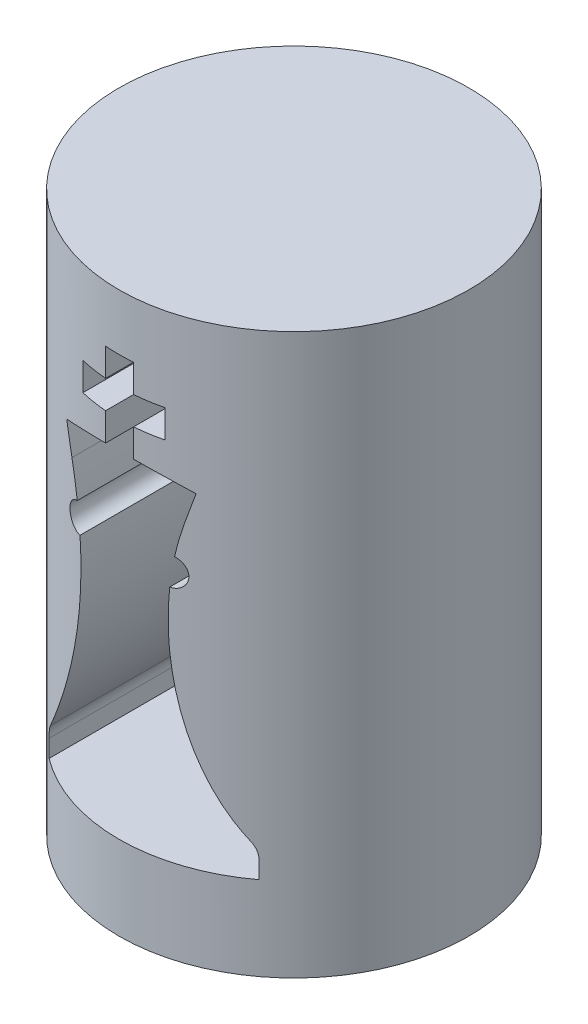
from build123d import *

# Parameters (mm, degrees)
SKETCH2_R               = 12.5
BOSS_EXTRUDE1_DEPTH     = 20
CUT_EXTRUDE1_DEPTH      = 13.5
CUT_EXTRUDE1_DEPTH_BACK = 13.5
SKETCH4_R               = 3
CUT_EXTRUDE2_DEPTH      = 3


with BuildPart() as part:
    # Sketch2 → Boss-Extrude1 (new body, symmetric)
    with BuildSketch(Plane(origin=(0, 0, 0), x_dir=(1, 0, 0), z_dir=(0, 1, 0))):
        Circle(SKETCH2_R)
    extrude(amount=BOSS_EXTRUDE1_DEPTH, both=True)

    # Sketch3 → Cut-Extrude1 (cut, two sides)
    with BuildSketch(Plane.XY) as cut_extrude1_sk:
        with BuildLine():
            Line((-7.5, -14), (7.5, -14))
            Line((7.5, -14), (7.5, -12.75))
            ThreePointArc((7.5, -12.75), (7.412263886, -12.186373325), (7.157358145, -11.676083489))
            ThreePointArc((7.157358145, -11.676083489), (3.865958131, -4.691681234), (3.204614294, 3.001030462))
            ThreePointArc((3.204614294, 3.001030462), (4.240621129, 3.863362603), (3.476741803, 4.973954904))
            ThreePointArc((3.476741803, 4.973954904), (3.722208484, 6.12821111), (4.029528967, 7.267559785))
            Line((4.029528967, 7.267559785), (4.622243509, 9.250708497))
            ThreePointArc((4.622243509, 9.250708497), (2.835976896, 9.745509591), (1, 10))
            Line((1, 10), (1, 12))
            Line((1, 12), (2.92625895, 12))
            Line((2.92625895, 12), (2.92625895, 14))
            Line((2.92625895, 14), (1, 14))
            Line((1, 14), (1, 16))
            Line((1, 16), (-1, 16))
            Line((-1, 16), (-1, 14))
            Line((-1, 14), (-2.92625895, 14))
            Line((-2.92625895, 14), (-2.92625895, 12))
            Line((-2.92625895, 12), (-1, 12))
            Line((-1, 12), (-1, 10))
            ThreePointArc((-1, 10), (-2.835976896, 9.745509591), (-4.622243509, 9.250708497))
            Line((-4.622243509, 9.250708497), (-4.029528967, 7.267559785))
            ThreePointArc((-4.029528967, 7.267559785), (-3.722208484, 6.12821111), (-3.476741803, 4.973954904))
            ThreePointArc((-3.476741803, 4.973954904), (-4.240621129, 3.863362603), (-3.204614294, 3.001030462))
            ThreePointArc((-3.204614294, 3.001030462), (-3.865958131, -4.691681234), (-7.157358145, -11.676083489))
            ThreePointArc((-7.157358145, -11.676083489), (-7.412263886, -12.186373325), (-7.5, -12.75))
            Line((-7.5, -12.75), (-7.5, -14))
        make_face()
    extrude(amount=CUT_EXTRUDE1_DEPTH, mode=Mode.SUBTRACT)
    extrude(cut_extrude1_sk.sketch, amount=-CUT_EXTRUDE1_DEPTH_BACK, mode=Mode.SUBTRACT)

    # Sketch4 → Cut-Extrude2 (cut)
    with BuildSketch(Plane(origin=(0, -20, 0), x_dir=(-1, 0, 0), z_dir=(0, -1, 0))):
        Circle(SKETCH4_R)
    extrude(amount=-CUT_EXTRUDE2_DEPTH, mode=Mode.SUBTRACT)


solid = part.part
